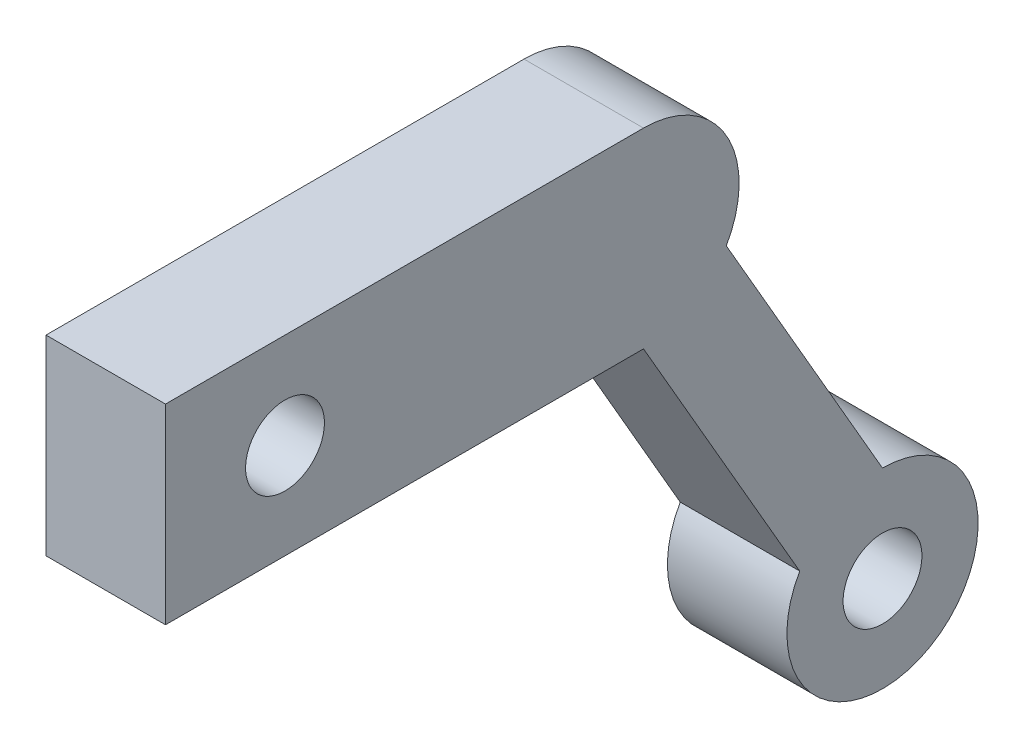
from build123d import *

# Parameters (mm, degrees)
EXTRUDE_1_DEPTH     = 5
SKETCH_2_R          = 1.65
CUT_EXTRUDE_1_DEPTH = 10


with BuildPart() as part:
    # 草图1 → 凸台-拉伸1 (new body)
    with BuildSketch(Plane(origin=(0, 0, 0), x_dir=(0, 0, -1), z_dir=(1, 0, 0))):
        with BuildLine():
            ThreePointArc((20, -8), (16, -4), (20, 0))
            Line((20, 0), (0, 0))
            Line((0, 0), (0, -8))
            Line((0, -8), (20, -8))
        make_face()
        with BuildLine():
            Line((20, -8), (20, 0))
            ThreePointArc((20, 0), (16, -4), (20, -8))
        make_face()
        with BuildLine():
            Line((23.464101615, -6), (20, 0))
            Line((20, 0), (20, -8))
            ThreePointArc((20, -8), (22, -7.464101615), (23.464101615, -6))
        make_face()
        with BuildLine():
            ThreePointArc((24, -4), (22.828427125, -1.171572875), (20, 0))
            Line((20, 0), (23.464101615, -6))
            ThreePointArc((23.464101615, -6), (23.863703305, -5.03527618), (24, -4))
        make_face()
        with BuildLine():
            Line((30, -17.320508076), (23.464101615, -6))
            ThreePointArc((23.464101615, -6), (22, -7.464101615), (20, -8))
            Line((20, -8), (26.535898385, -19.320508076))
            ThreePointArc((26.535898385, -19.320508076), (28, -17.856406461), (30, -17.320508076))
        make_face()
        with BuildLine():
            ThreePointArc((34, -21.320508076), (32.828427125, -18.492080951), (30, -17.320508076))
            Line((30, -17.320508076), (30, -25.320508076))
            ThreePointArc((30, -25.320508076), (32.828427125, -24.1489352), (34, -21.320508076))
        make_face()
        with BuildLine():
            Line((30, -25.320508076), (30, -17.320508076))
            ThreePointArc((30, -17.320508076), (28, -17.856406461), (26.535898385, -19.320508076))
            Line((26.535898385, -19.320508076), (30, -25.320508076))
        make_face()
        with BuildLine():
            Line((30, -25.320508076), (26.535898385, -19.320508076))
            ThreePointArc((26.535898385, -19.320508076), (26.535898385, -23.320508076), (30, -25.320508076))
        make_face()
    extrude(amount=EXTRUDE_1_DEPTH)

    # 草图2 → 切除-拉伸1 (cut)
    with BuildSketch(Plane(origin=(5, 0, 0), x_dir=(0, 0, -1), z_dir=(1, 0, 0))):
        with Locations((5, -4)):
            Circle(SKETCH_2_R)
        with Locations((30, -21.320508076)):
            Circle(SKETCH_2_R)
    extrude(amount=-CUT_EXTRUDE_1_DEPTH, mode=Mode.SUBTRACT)


solid = part.part
